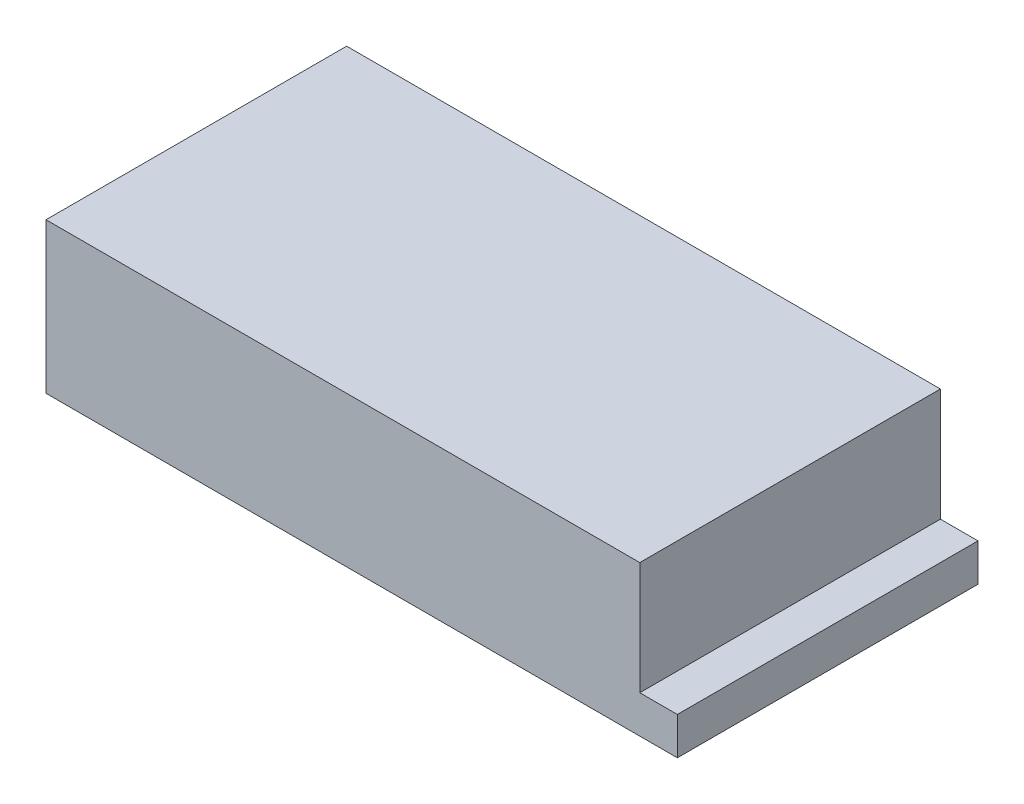
from build123d import *

# Parameters (mm, degrees)
EXTRUDE_1_DEPTH = 80


with BuildPart() as part:
    # 草图1 → 凸台-拉伸1 (new body)
    with BuildSketch(Plane.XY):
        Polygon((-48.38249244, 0), (119.61750756, 0), (119.61750756, 10), (109.61750756, 10), (109.61750756, 40), (-48.38249244, 40), align=None)
    extrude(amount=EXTRUDE_1_DEPTH)


solid = part.part
